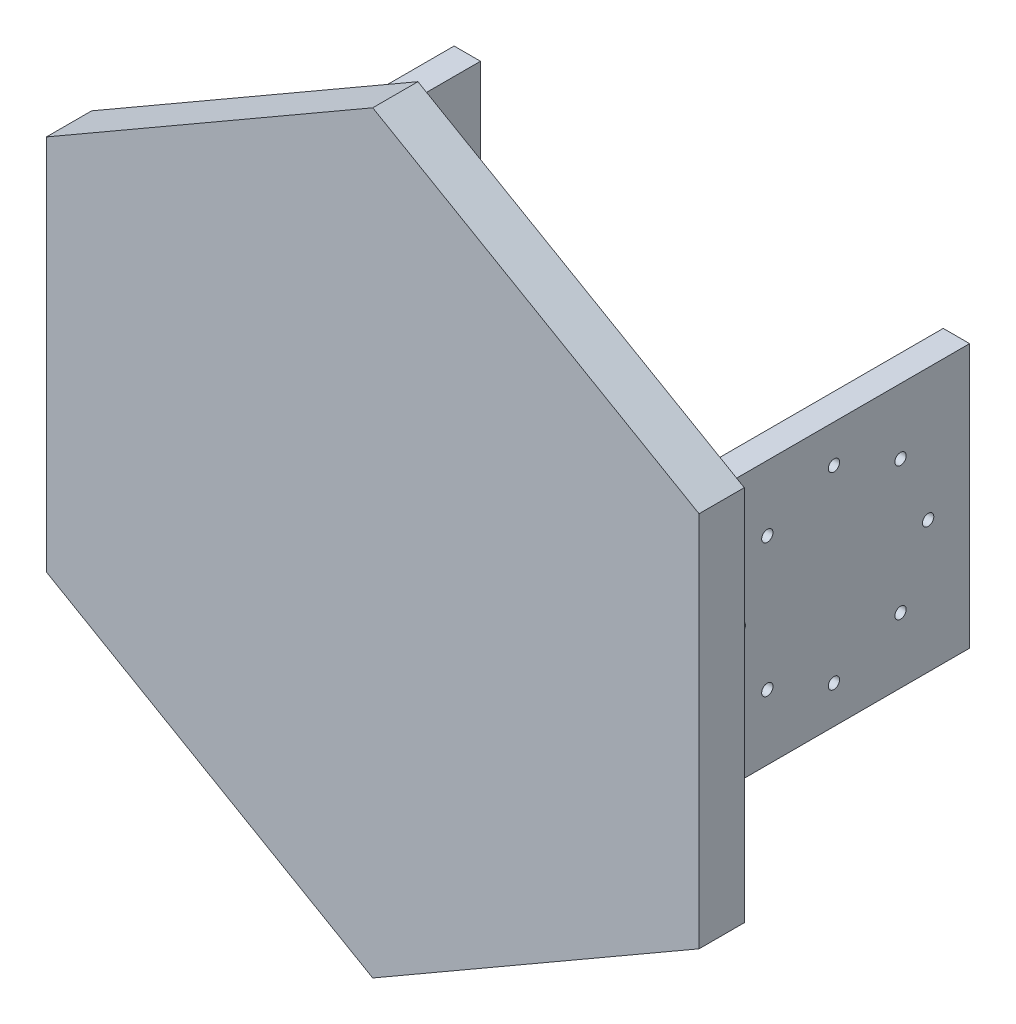
from build123d import *

# Parameters (mm, degrees)
BOSS_EXTRUDE1_DEPTH = 17.5
SKETCH2_R           = 0.75
CUT_EXTRUDE1_DEPTH  = 68.4
SKETCH2_3_R         = 0.75
CUT_EXTRUDE2_DEPTH  = 69.4
SKETCH3_W           = 82.6
SKETCH3_H           = 35
BOSS_EXTRUDE2_DEPTH = 6
BOSS_EXTRUDE3_DEPTH = 6


with BuildPart() as part:
    # Sketch1 → Boss-Extrude1 (new body, symmetric)
    with BuildSketch(Plane(origin=(0, 0, 0), x_dir=(1, 0, 0), z_dir=(0, 1, 0))):
        with BuildLine():
            Line((-29.2, 0), (29.2, 0))
            ThreePointArc((29.2, 0), (32.735533906, 1.464466094), (34.2, 5))
            Line((34.2, 5), (34.2, 45))
            Line((34.2, 45), (30.7, 45))
            Line((30.7, 45), (30.7, 10))
            ThreePointArc((30.7, 10), (29.235533906, 6.464466094), (25.7, 5))
            Line((25.7, 5), (-25.7, 5))
            ThreePointArc((-25.7, 5), (-29.235533906, 6.464466094), (-30.7, 10))
            Line((-30.7, 10), (-30.7, 45))
            Line((-30.7, 45), (-34.2, 45))
            Line((-34.2, 45), (-34.2, 5))
            ThreePointArc((-34.2, 5), (-32.735533906, 1.464466094), (-29.2, 0))
        make_face()
    extrude(amount=BOSS_EXTRUDE1_DEPTH, both=True)

    # Sketch2 → Cut-Extrude1 (cut)
    with BuildSketch(Plane.ZY.offset(34.2)):
        with Locations((-27, 12.5)):
            Circle(SKETCH2_R)
        with Locations((-18.161165235, 8.838834765)):
            Circle(SKETCH2_R)
        with Locations((-14.5, 0)):
            Circle(SKETCH2_R)
        with Locations((-18.161165235, -8.838834765)):
            Circle(SKETCH2_R)
        with Locations((-35.838834765, -8.838834765)):
            Circle(SKETCH2_R)
        with Locations((-39.5, 0)):
            Circle(SKETCH2_R)
        with Locations((-35.838834765, 8.838834765)):
            Circle(SKETCH2_R)
    extrude(amount=-CUT_EXTRUDE1_DEPTH, mode=Mode.SUBTRACT)

    # Sketch2_3 → Cut-Extrude2 (cut, through all)
    with BuildSketch(Plane.ZY.offset(34.2)):
        with Locations((-27, -12.5)):
            Circle(SKETCH2_3_R)
    extrude(amount=-CUT_EXTRUDE2_DEPTH, mode=Mode.SUBTRACT)

    # Sketch3 → Boss-Extrude2 (add)
    with BuildSketch(Plane.XY):
        Rectangle(SKETCH3_W, SKETCH3_H)
    extrude(amount=-BOSS_EXTRUDE2_DEPTH)

    # Sketch5 → Boss-Extrude3 (add)
    with BuildSketch(Plane.XY):
        Polygon((43.301270189, 25), (0, 50), (-43.301270189, 25), (-43.301270189, -25), (0, -50), (43.301270189, -25), align=None)
    extrude(amount=-BOSS_EXTRUDE3_DEPTH)


solid = part.part
